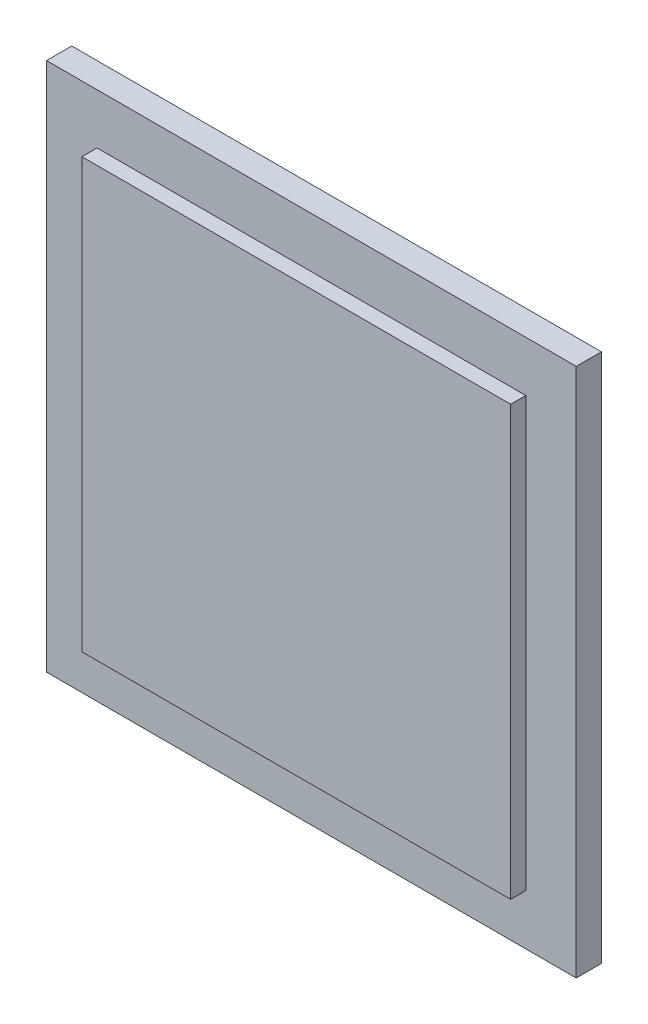
from build123d import *

# Parameters (mm, degrees)
SKETCH1_W           = 105
SKETCH1_H           = 105
BOSS_EXTRUDE1_DEPTH = 5
SKETCH2_W           = 85
SKETCH2_H           = 85
BOSS_EXTRUDE2_DEPTH = 3


with BuildPart() as part:
    # Sketch1 → Boss-Extrude1 (new body)
    with BuildSketch(Plane.XY):
        Rectangle(SKETCH1_W, SKETCH1_H)
    extrude(amount=BOSS_EXTRUDE1_DEPTH)

    # Sketch2 → Boss-Extrude2 (add)
    with BuildSketch(Plane.XY.offset(5)):
        Rectangle(SKETCH2_W, SKETCH2_H)
    extrude(amount=BOSS_EXTRUDE2_DEPTH)


solid = part.part
